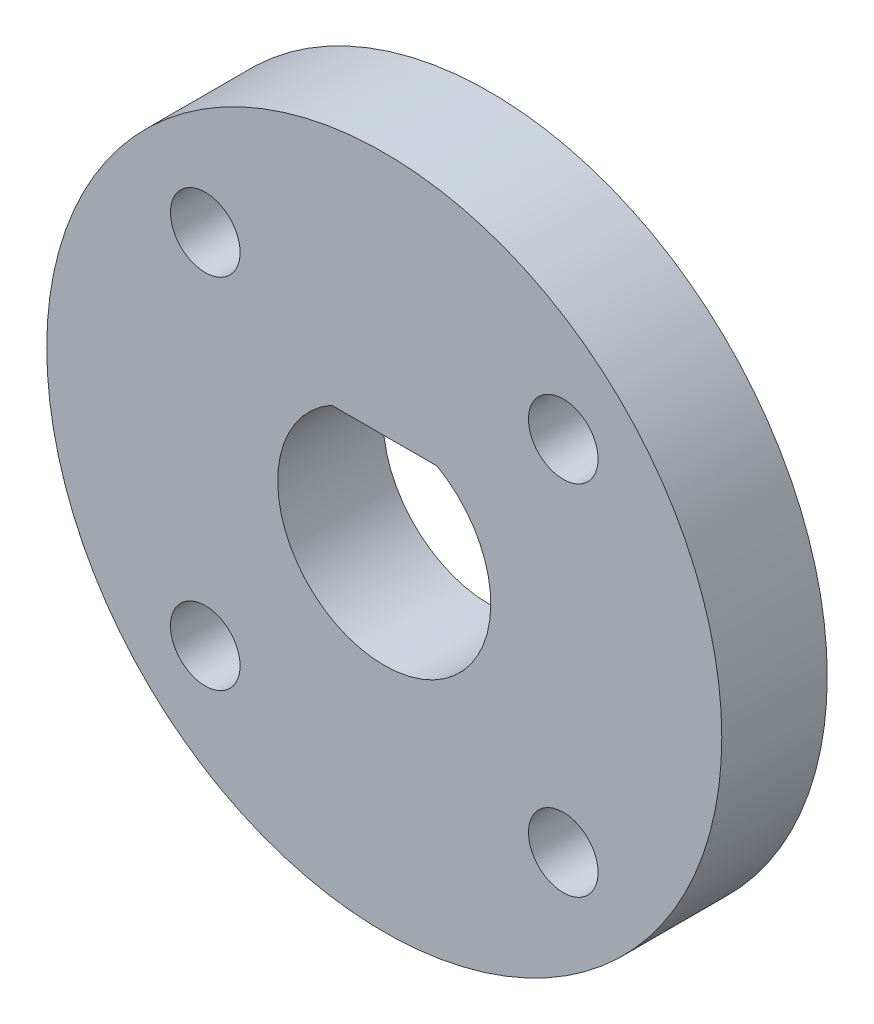
from build123d import *

# Parameters (mm, degrees)
SKETCH1_R                   = 16
BOSS_EXTRUDE1_DEPTH         = 2.5
TAP_DRILL_FOR_M4X0_7_TAP1_D = 3.3


with BuildPart() as part:
    # Sketch1 → Boss-Extrude1 (new body, symmetric)
    with BuildSketch(Plane.XY):
        Circle(SKETCH1_R)
        with BuildLine():
            Line((-2.5, 4.387767086), (2.5, 4.387767086))
            ThreePointArc((2.5, 4.387767086), (0, -5.05), (-2.5, 4.387767086))
        make_face(mode=Mode.SUBTRACT)
    extrude(amount=BOSS_EXTRUDE1_DEPTH, both=True)

    # Tap Drill for M4x0.7 Tap1 (through all)
    with Locations(Plane.XY.offset(2.5)):
        with Locations((8.485281374, 8.485281374), (-8.485281374, 8.485281374), (-8.485281374, -8.485281374), (8.485281374, -8.485281374)):
            Hole(TAP_DRILL_FOR_M4X0_7_TAP1_D / 2)


solid = part.part
